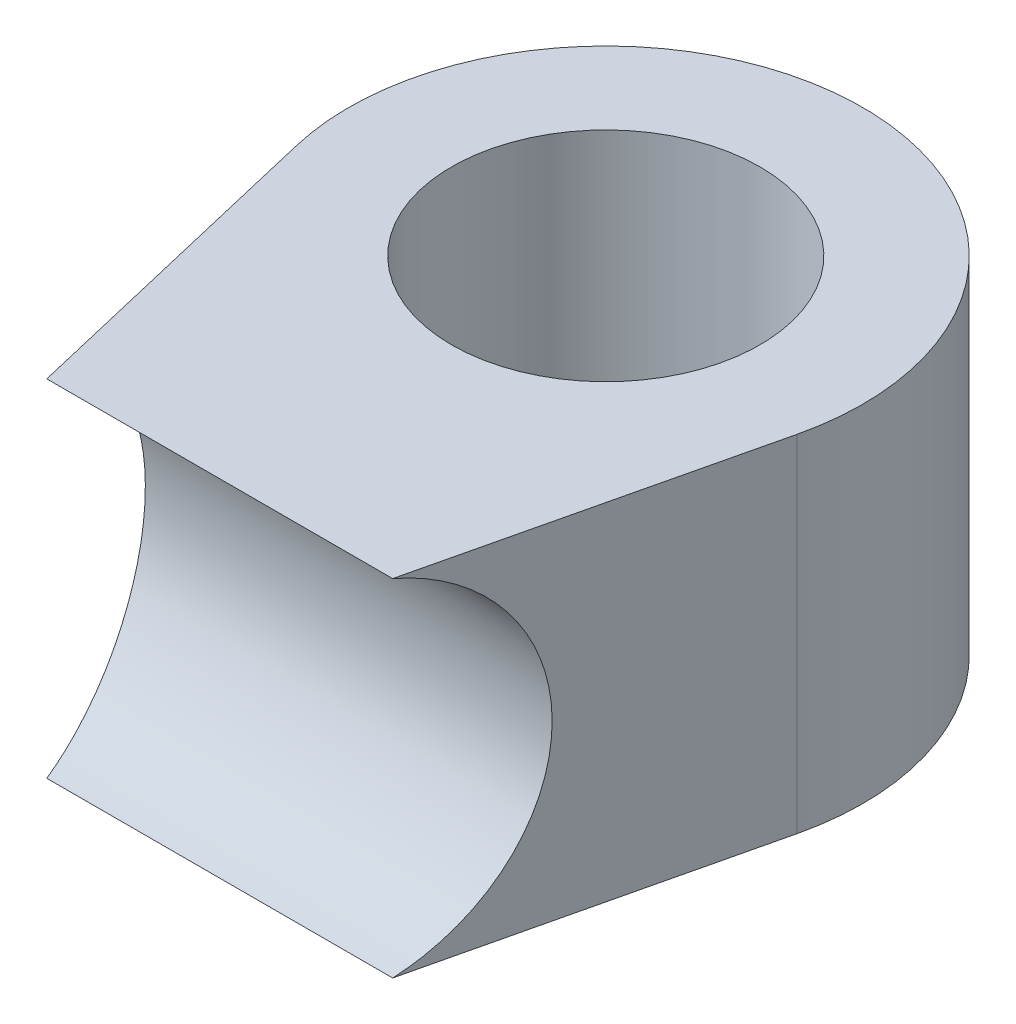
from build123d import *

# Parameters (mm, degrees)
CROQUIS1_R                 = 3
SALIENTE_EXTRUIR2_DEPTH    = 10
CROQUIS2_R                 = 3.51
CORTAR_EXTRUIR1_DEPTH      = 6
CORTAR_EXTRUIR1_DEPTH_BACK = 6
CORTAR_EXTRUIR2_DEPTH      = 13.51


with BuildPart() as part:
    # Croquis1 → Saliente-Extruir2 (new body)
    with BuildSketch(Plane(origin=(0, 0, 0), x_dir=(1, 0, 0), z_dir=(0, 1, 0))):
        with BuildLine():
            ThreePointArc((4.866240612, 7.361217033), (0, 13.51), (-4.866240612, 7.361217033))
            Line((-4.866240612, 7.361217033), (-3.364535629, 1))
            Line((-3.364535629, 1), (3.364535629, 1))
            Line((3.364535629, 1), (4.866240612, 7.361217033))
        make_face()
        with Locations((0, 8.51)):
            Circle(CROQUIS1_R, mode=Mode.SUBTRACT)
    extrude(amount=SALIENTE_EXTRUIR2_DEPTH)

    # Croquis2 → Cortar-Extruir1 (cut, two sides)
    with BuildSketch(Plane(origin=(0, 0, 0), x_dir=(0, 0, -1), z_dir=(1, 0, 0))) as cortar_extruir1_sk:
        with Locations((0, 3.364535629)):
            Circle(CROQUIS2_R)
    extrude(amount=CORTAR_EXTRUIR1_DEPTH, mode=Mode.SUBTRACT)
    extrude(cortar_extruir1_sk.sketch, amount=-CORTAR_EXTRUIR1_DEPTH_BACK, mode=Mode.SUBTRACT)

    # Croquis4 → Cortar-Extruir2 (cut, through all)
    with BuildSketch(Plane.XY.offset(-1)):
        Polygon((-10.381986268, 6.729071258), (12.651385212, 6.729071258), (6.885028009, 11.685095577), (-4.618478965, 12.095500912), align=None)
    extrude(amount=-CORTAR_EXTRUIR2_DEPTH, mode=Mode.SUBTRACT)


solid = part.part
